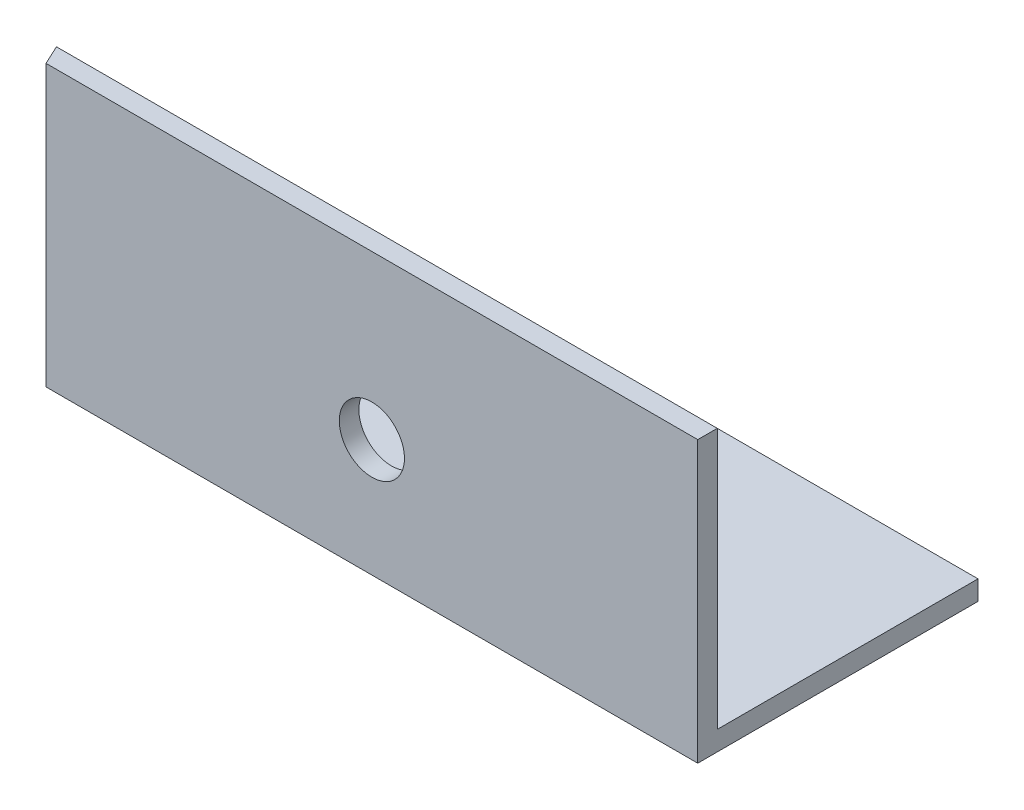
from build123d import *

# Parameters (mm, degrees)
EXTRUDE_1_DEPTH     = 120
CUT_EXTRUDE_1_DEPTH = 50
SKETCH_3_R          = 5
CUT_EXTRUDE_2_DEPTH = 10


with BuildPart() as part:
    # Эскиз1 → Вытянуть-Тонкостенный1 (new body)
    with BuildSketch(Plane(origin=(0, 0, 0), x_dir=(0, 0, -1), z_dir=(1, 0, 0))):
        Polygon((0, 40), (0, 0), (40, 0), (40, -3), (-3, -3), (-3, 40), align=None)
    extrude(amount=EXTRUDE_1_DEPTH)

    # Эскиз2 → Вырез-Вытянуть1 (cut)
    with BuildSketch(Plane(origin=(0, -3, 0), x_dir=(1, 0, 0), z_dir=(0, 1, 0))):
        Polygon((0, 40), (20, -3), (0, -3), align=None)
    extrude(amount=CUT_EXTRUDE_1_DEPTH, mode=Mode.SUBTRACT)

    # Эскиз3 → Вырез-Вытянуть2 (cut)
    with BuildSketch(Plane.XY.offset(3)):
        with Locations((70, 15)):
            Circle(SKETCH_3_R)
    extrude(amount=-CUT_EXTRUDE_2_DEPTH, mode=Mode.SUBTRACT)


solid = part.part
